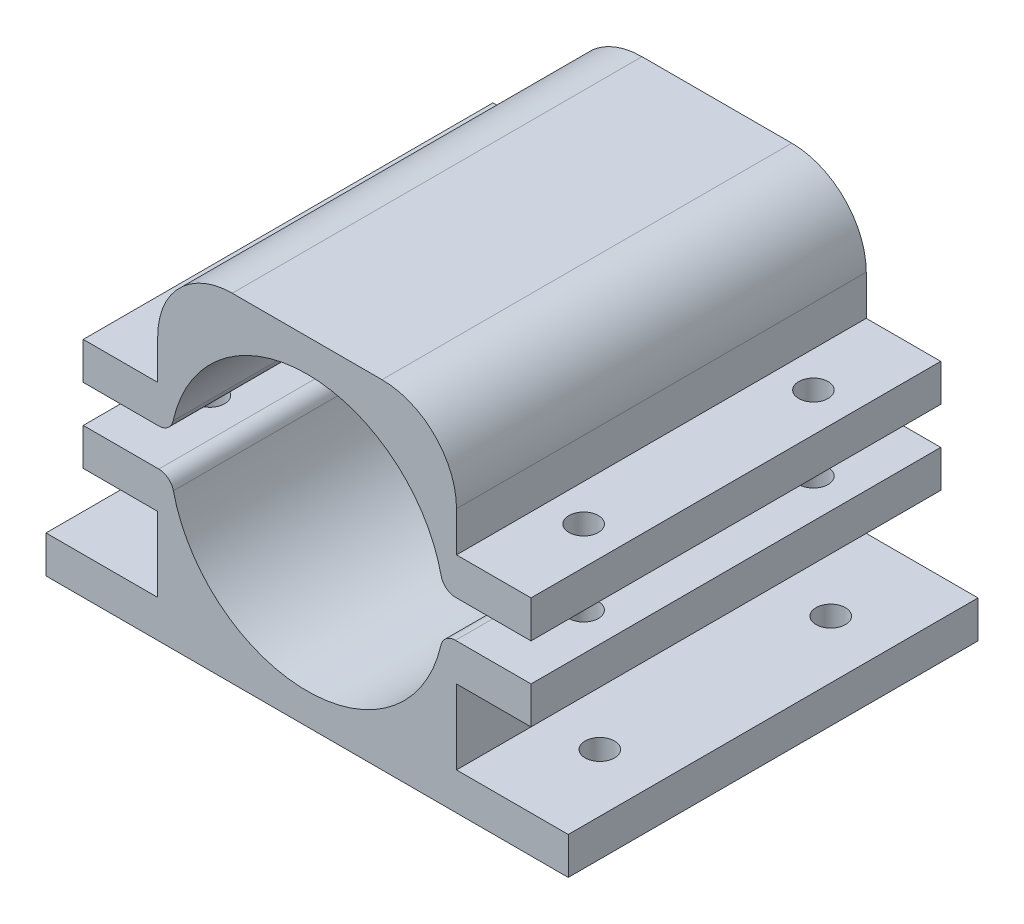
from build123d import *

# Parameters (mm, degrees)
BOSS_EXTRUDE1_DEPTH   = 55
BOSS_EXTRUDE1_2_DEPTH = 55
FILLET1_R             = 10
FILLET2_R             = 2
FILLET3_R             = 2
SKETCH3_R             = 1.975
CUT_EXTRUDE1_DEPTH    = 15
SKETCH5_R             = 1.975
CUT_EXTRUDE2_DEPTH    = 5


with BuildPart() as part:
    # Sketch1 → Boss-Extrude1 (new body)
    with BuildSketch(Plane.XY):
        with BuildLine():
            Line((-34.918673845, -5.897830648), (-34.918673845, -10.897830648))
            Line((-34.918673845, -10.897830648), (35.185897583, -10.897830648))
            Line((35.185897583, -10.897830648), (35.185897583, -5.897830648))
            Line((35.185897583, -5.897830648), (20.185897583, -5.897830648))
            Line((20.185897583, -5.897830648), (20.185897583, 4.102169352))
            Line((20.185897583, 4.102169352), (30.185897583, 4.102169352))
            Line((30.185897583, 4.102169352), (30.185897583, 9.102169352))
            Line((30.185897583, 9.102169352), (18.378479649, 9.102169352))
            ThreePointArc((18.378479649, 9.102169352), (0.133611869, -6.752728571), (-18.111255911, 9.102169352))
            Line((-18.111255911, 9.102169352), (-29.918673845, 9.102169352))
            Line((-29.918673845, 9.102169352), (-29.918673845, 4.102169352))
            Line((-29.918673845, 4.102169352), (-19.918673845, 4.102169352))
            Line((-19.918673845, 4.102169352), (-19.918673845, -5.897830648))
            Line((-19.918673845, -5.897830648), (-34.918673845, -5.897830648))
        make_face()
    extrude(amount=BOSS_EXTRUDE1_DEPTH)

    # Fillet2
    fillet2_edges = [part.edges().sort_by_distance(p)[0] for p in [
        (18.378479649, 9.102169352, 27.5),
        (-18.111255911, 9.102169352, 27.5),
    ]]
    fillet(fillet2_edges, radius=FILLET2_R)


with BuildPart() as body_2:
    # Sketch1 → Boss-Extrude1 2 (new body)
    with BuildSketch(Plane.XY):
        with BuildLine():
            Line((-29.918673845, 14.102169352), (-18.130457258, 14.102169352))
            ThreePointArc((-18.130457258, 14.102169352), (0.133611869, 30.097271429), (18.397680996, 14.102169352))
            Line((18.397680996, 14.102169352), (30.185897583, 14.102169352))
            Line((30.185897583, 14.102169352), (30.185897583, 19.102169352))
            Line((30.185897583, 19.102169352), (20.185897583, 19.102169352))
            Line((20.185897583, 19.102169352), (20.185897583, 34.468440781))
            Line((20.185897583, 34.468440781), (-19.918673845, 34.468440781))
            Line((-19.918673845, 34.468440781), (-19.918673845, 19.102169352))
            Line((-19.918673845, 19.102169352), (-29.918673845, 19.102169352))
            Line((-29.918673845, 19.102169352), (-29.918673845, 14.102169352))
        make_face()
    extrude(amount=BOSS_EXTRUDE1_2_DEPTH)

    # Fillet1
    fillet1_edges = [body_2.edges().sort_by_distance(p)[0] for p in [
        (-19.918673845, 34.468440781, 27.5),
        (20.185897583, 34.468440781, 27.5),
    ]]
    fillet(fillet1_edges, radius=FILLET1_R)

    # Fillet3
    fillet3_edges = [body_2.edges().sort_by_distance(p)[0] for p in [
        (-18.130457258, 14.102169352, 27.5),
        (18.397680996, 14.102169352, 27.5),
    ]]
    fillet(fillet3_edges, radius=FILLET3_R)


with BuildPart() as cut_extrude1_tool:
    # Sketch3 → Cut-Extrude1 (new body)
    with BuildSketch(Plane(origin=(0, 19.102169352, 0), x_dir=(1, 0, 0), z_dir=(0, 1, 0))):
        with Locations((-24.918673845, -12)):
            Circle(SKETCH3_R)
        with Locations((-24.918673845, -43)):
            Circle(SKETCH3_R)
        with Locations((25.127298875, -42.878422983)):
            Circle(SKETCH3_R)
        with Locations((24.976682747, -11.878788875)):
            Circle(SKETCH3_R)
    extrude(amount=-CUT_EXTRUDE1_DEPTH)


with BuildPart() as part_1:
    add(part.part)

    # Cut-Extrude1: cut by cut_extrude1_tool
    add(cut_extrude1_tool.part, mode=Mode.SUBTRACT)

    # Sketch5 → Cut-Extrude2 (cut)
    with BuildSketch(Plane(origin=(0, -10.897830648, 0), x_dir=(-1, 0, 0), z_dir=(0, -1, 0))):
        with Locations((27.418673845, -43)):
            Circle(SKETCH5_R)
        with Locations((27.418673845, -12)):
            Circle(SKETCH5_R)
        with Locations((-27.418673845, -12)):
            Circle(SKETCH5_R)
        with Locations((-27.418673845, -43)):
            Circle(SKETCH5_R)
    extrude(amount=-CUT_EXTRUDE2_DEPTH, mode=Mode.SUBTRACT)


with BuildPart() as body_2_1:
    add(body_2.part)

    # Cut-Extrude1: cut by cut_extrude1_tool
    add(cut_extrude1_tool.part, mode=Mode.SUBTRACT)


solid = Compound([part_1.part, body_2_1.part])
